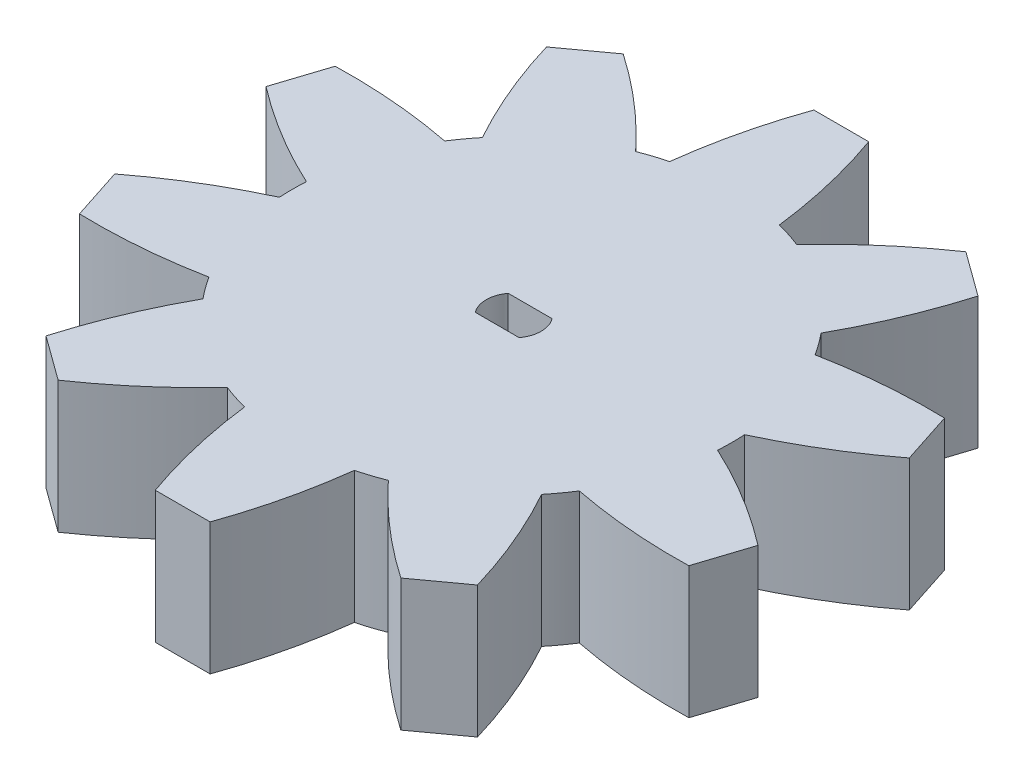
from build123d import *

# Parameters (mm, degrees)
SKETCH1_R           = 20
BOSS_EXTRUDE1_DEPTH = 12
CUT_EXTRUDE1_DEPTH  = 6
BOSS_EXTRUDE2_DEPTH = 12
CIRPATTERN2_COUNT   = 10


with BuildPart() as part:
    # Sketch1 → Boss-Extrude1 (new body)
    with BuildSketch(Plane(origin=(0, 0, 0), x_dir=(1, 0, 0), z_dir=(0, 1, 0))):
        Circle(SKETCH1_R)
    extrude(amount=BOSS_EXTRUDE1_DEPTH)

    # Sketch2 → Cut-Extrude1 (cut)
    with BuildSketch(Plane(origin=(0, 12, 0), x_dir=(1, 0, 0), z_dir=(0, 1, 0))):
        with BuildLine():
            Line((-1.960372744, 1.614176032), (2.039627256, 1.614176032))
            ThreePointArc((2.039627256, 1.614176032), (2.539627256, 0.114176032), (2.039627256, -1.385823968))
            Line((2.039627256, -1.385823968), (-1.960372744, -1.385823968))
            ThreePointArc((-1.960372744, -1.385823968), (-2.460372744, 0.114176032), (-1.960372744, 1.614176032))
        make_face()
    extrude(amount=-CUT_EXTRUDE1_DEPTH, mode=Mode.SUBTRACT)

    # Sketch4 → Boss-Extrude2 (add)
    with BuildSketch(Plane(origin=(0, 12, 0), x_dir=(1, 0, 0), z_dir=(0, 1, 0))):
        with BuildLine():
            Line((-2.5, 30), (2.5, 30))
            ThreePointArc((2.5, 30), (4.041341884, 24.750944403), (5, 19.364916731))
            ThreePointArc((5, 19.364916731), (0, 20), (-5, 19.364916731))
            ThreePointArc((-5, 19.364916731), (-4.041341884, 24.750944403), (-2.5, 30))
        make_face()
    boss_extrude2 = extrude(amount=-BOSS_EXTRUDE2_DEPTH)

    # CirPattern2: Boss-Extrude2 ×10 about axis
    cirpattern2_axis = Axis((0, 0, 0), (0, 1, 0))
    for i in range(1, CIRPATTERN2_COUNT):
        add(boss_extrude2.rotate(cirpattern2_axis, i * 360 / CIRPATTERN2_COUNT))


solid = part.part
